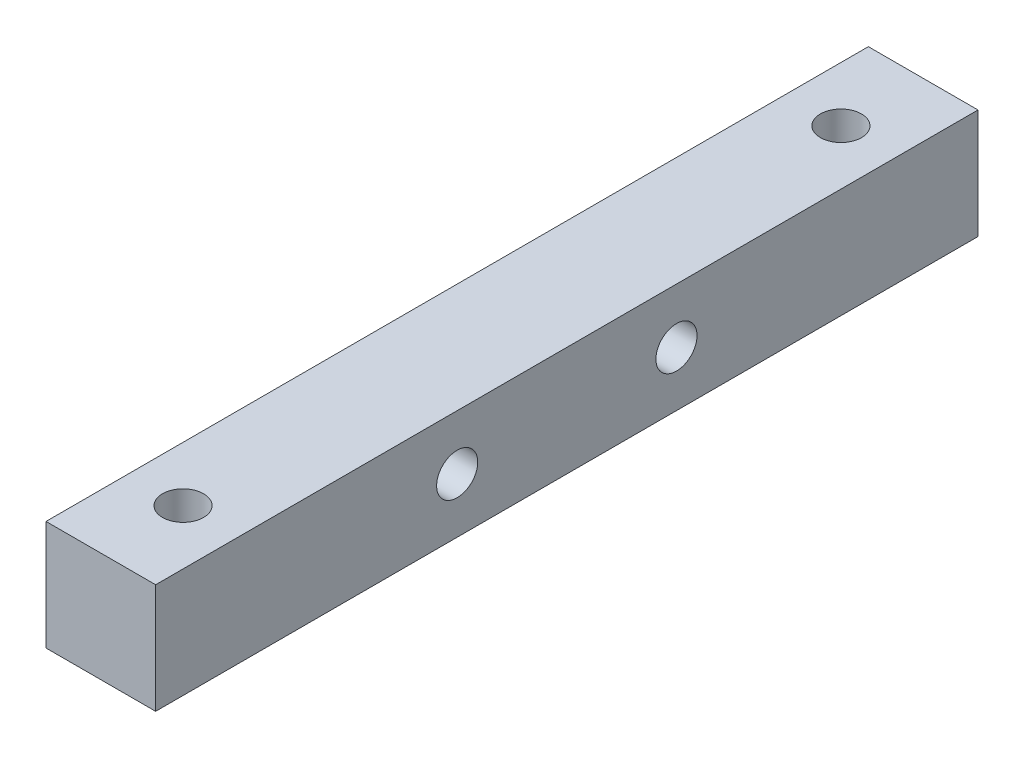
from build123d import *

# Parameters (mm, degrees)
CROQUIS1_W                   = 10
CROQUIS1_H                   = 10
SALIENTE_EXTRUIR1_DEPTH      = 37.5
TALADRO_DE_MARGEN_PARA_M33_D = 3.75
TALADRO_DE_MARGEN_PARA_M34_D = 3.75
CORTAR_EXTRUIR4_DEPTH        = 3.2
CORTAR_EXTRUIR5_DEPTH        = 3.2


with BuildPart() as part:
    # Croquis1 → Saliente-Extruir1 (new body, symmetric)
    with BuildSketch(Plane.XY):
        Rectangle(CROQUIS1_W, CROQUIS1_H)
    extrude(amount=SALIENTE_EXTRUIR1_DEPTH, both=True)

    # Taladro de margen para M33 (through all)
    with Locations(Plane.ZY.offset(5)):
        with Locations((-10, 0), (10, 0)):
            Hole(TALADRO_DE_MARGEN_PARA_M33_D / 2)

    # Taladro de margen para M34 (through all)
    with Locations(Plane(origin=(0, -5, 0), x_dir=(-1, 0, 0), z_dir=(0, -1, 0))):
        with Locations((0, 30), (0, -30)):
            Hole(TALADRO_DE_MARGEN_PARA_M34_D / 2)

    # Croquis19 → Cortar-Extruir4 (cut)
    with BuildSketch(Plane.XZ.offset(5)):
        Polygon((2.771281292, -28.4), (0, -26.8), (-2.771281292, -28.4), (-2.771281292, -31.6), (0, -33.2), (2.771281292, -31.6), align=None)
        Polygon((2.771281292, 31.6), (0, 33.2), (-2.771281292, 31.6), (-2.771281292, 28.4), (0, 26.8), (2.771281292, 28.4), align=None)
    extrude(amount=-CORTAR_EXTRUIR4_DEPTH, mode=Mode.SUBTRACT)

    # Croquis20 → Cortar-Extruir5 (cut)
    with BuildSketch(Plane.ZY.offset(5)):
        Polygon((-8.4, -2.771281292), (-6.8, 0), (-8.4, 2.771281292), (-11.6, 2.771281292), (-13.2, 0), (-11.6, -2.771281292), align=None)
        Polygon((11.6, -2.771281292), (13.2, 0), (11.6, 2.771281292), (8.4, 2.771281292), (6.8, 0), (8.4, -2.771281292), align=None)
    extrude(amount=-CORTAR_EXTRUIR5_DEPTH, mode=Mode.SUBTRACT)


solid = part.part
